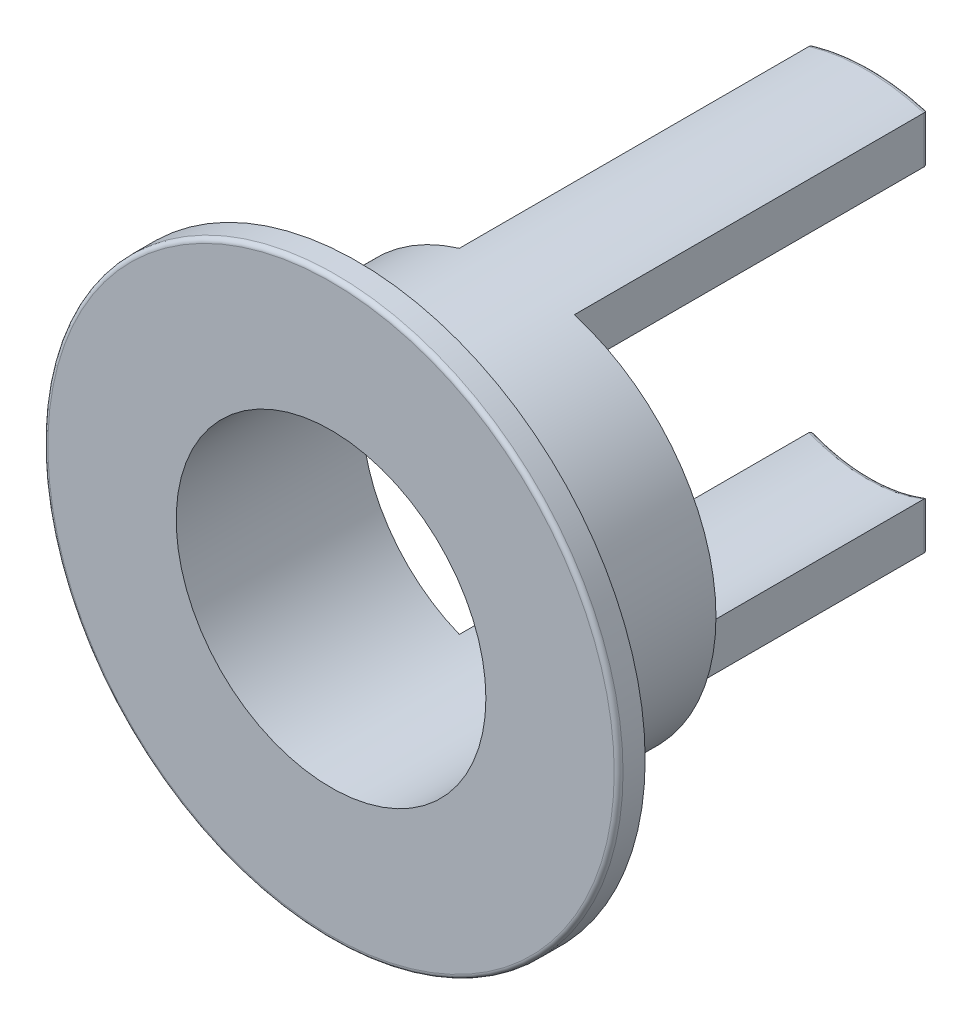
from build123d import *

# Parameters (mm, degrees)
SKETCH_1_R          = 3.25
SKETCH_1_R_2        = 2.25
SKETCH_1_R_3        = 1.75
EXTRUDE_1_DEPTH     = 0.3
SKETCH_1_4_R        = 2.25
SKETCH_1_4_R_2      = 1.75
EXTRUDE_2_DEPTH     = 5.8
CUT_EXTRUDE_1_DEPTH = 4
FILLET_1_R          = 0.05


with BuildPart() as part:
    # Sketch 1 → Extrude 1 (new body)
    with BuildSketch(Plane.XY):
        Circle(SKETCH_1_R)
        Circle(SKETCH_1_R_2, mode=Mode.SUBTRACT)
        Circle(SKETCH_1_R_2)
        Circle(SKETCH_1_R_3, mode=Mode.SUBTRACT)
    extrude(amount=EXTRUDE_1_DEPTH)

    # Sketch 1_4 → Extrude 2 (add)
    with BuildSketch(Plane.XY):
        Circle(SKETCH_1_4_R)
        Circle(SKETCH_1_4_R_2, mode=Mode.SUBTRACT)
    extrude(amount=-EXTRUDE_2_DEPTH)

    # Sketch 2 → Cut-Extrude 1 (cut)
    with BuildSketch(Plane(origin=(0, 0, -5.8), x_dir=(-1, 0, 0), z_dir=(0, 0, -1))):
        with BuildLine():
            ThreePointArc((-0.65, 2.154065923), (-2.25, 0), (-0.65, -2.154065923))
            Line((-0.65, -2.154065923), (-0.65, -1.624807681))
            ThreePointArc((-0.65, -1.624807681), (-1.75, 0), (-0.65, 1.624807681))
            Line((-0.65, 1.624807681), (-0.65, 2.154065923))
        make_face()
        with BuildLine():
            Line((0.65, -1.624807681), (0.65, -2.154065923))
            ThreePointArc((0.65, -2.154065923), (1.806239187, -1.341640786), (2.25, 0))
            ThreePointArc((2.25, 0), (1.806239187, 1.341640786), (0.65, 2.154065923))
            Line((0.65, 2.154065923), (0.65, 1.624807681))
            ThreePointArc((0.65, 1.624807681), (1.449137675, 0.981070844), (1.75, 0))
            ThreePointArc((1.75, 0), (1.449137675, -0.981070844), (0.65, -1.624807681))
        make_face()
    extrude(amount=-CUT_EXTRUDE_1_DEPTH, mode=Mode.SUBTRACT)

    # Fillet 1
    fillet_1_edges = [part.edges().sort_by_distance(p)[0] for p in [
        (0, 1.75, -5.8),
        (0.65, -1.889436802, -5.8),
        (0.65, 1.889436802, -5.8),
        (0, -1.75, -5.8),
        (0, -2.25, -5.8),
        (-0.65, 1.889436802, -5.8),
        (-0.65, -1.889436802, -5.8),
        (-3.25, 0, 0.3),
        (0, 2.25, -5.8),
    ]]
    fillet(fillet_1_edges, radius=FILLET_1_R)


solid = part.part
